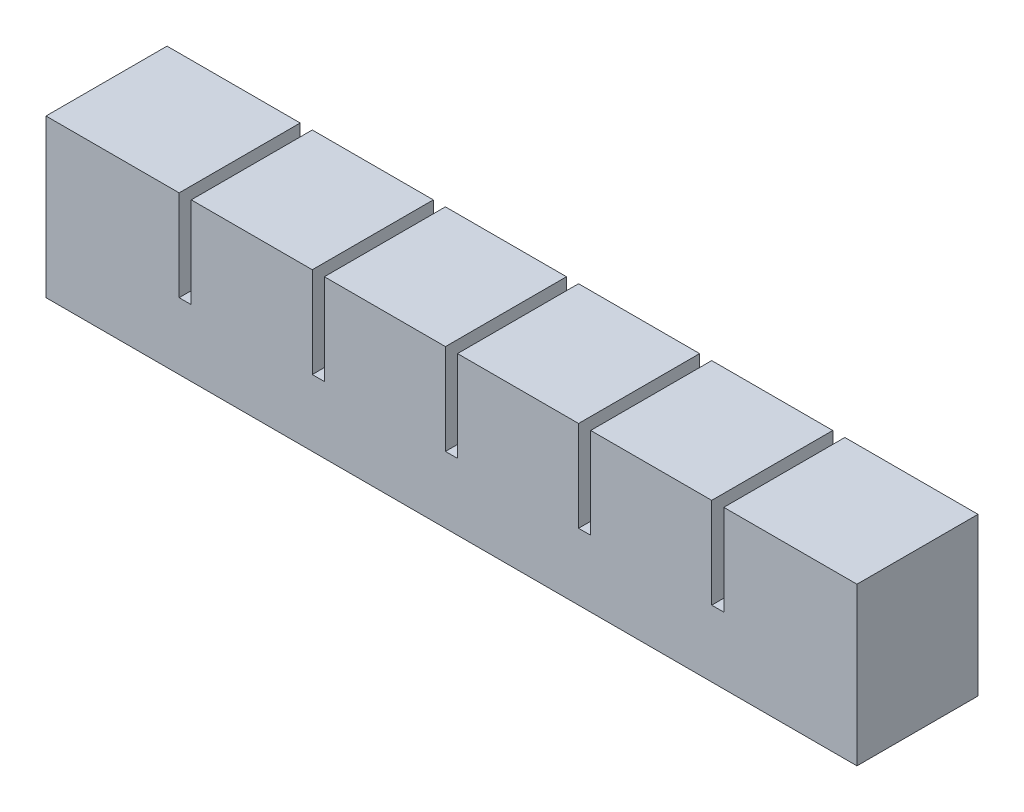
from build123d import *

# Parameters (mm, degrees)
SKETCH1_W           = 20
SKETCH1_H           = 20
BOSS_EXTRUDE1_DEPTH = 20
SKETCH2_W           = 10
SKETCH2_H           = 10
CUT_EXTRUDE1_DEPTH  = 15
SKETCH3_W           = 20
SKETCH3_H           = 5
BOSS_EXTRUDE2_DEPTH = 2
LPATTERN1_COUNT     = 6
LPATTERN1_PITCH     = 22
SKETCH4_W           = 20
SKETCH4_H           = 15
BOSS_EXTRUDE3_DEPTH = 2
SKETCH5_W           = 20
SKETCH5_H           = 20
BOSS_EXTRUDE5_DEPTH = 2
SKETCH7_W           = 120
SKETCH7_H           = 2
CUT_EXTRUDE2_DEPTH  = 2
SKETCH8_W           = 134
SKETCH8_H           = 20
BOSS_EXTRUDE6_DEPTH = 6


with BuildPart() as part:
    # Sketch1 → Boss-Extrude1 (new body)
    with BuildSketch(Plane.XY):
        with Locations((10, 10)):
            Rectangle(SKETCH1_W, SKETCH1_H)
    extrude(amount=BOSS_EXTRUDE1_DEPTH)

    # Sketch2 → Cut-Extrude1 (cut)
    with BuildSketch(Plane(origin=(0, 0, 0), x_dir=(-1, 0, 0), z_dir=(0, -1, 0))):
        with Locations((-10, -10)):
            Rectangle(SKETCH2_W, SKETCH2_H)
    extrude(amount=-CUT_EXTRUDE1_DEPTH, mode=Mode.SUBTRACT)

    # Sketch3 → Boss-Extrude2 (add)
    with BuildSketch(Plane(origin=(20, 0, 0), x_dir=(0, 0, -1), z_dir=(1, 0, 0))):
        with Locations((-10, 2.5)):
            Rectangle(SKETCH3_W, SKETCH3_H)
    extrude(amount=BOSS_EXTRUDE2_DEPTH)


with BuildPart() as lpattern1_1:
    # LPattern1: pattern copy
    add(part.part.moved(Location(Vector(1, 0, 0) * (1 * LPATTERN1_PITCH))))


with BuildPart() as lpattern1_2:
    # LPattern1: pattern copy
    add(part.part.moved(Location(Vector(1, 0, 0) * (2 * LPATTERN1_PITCH))))


with BuildPart() as lpattern1_3:
    # LPattern1: pattern copy
    add(part.part.moved(Location(Vector(1, 0, 0) * (3 * LPATTERN1_PITCH))))


with BuildPart() as lpattern1_4:
    # LPattern1: pattern copy
    add(part.part.moved(Location(Vector(1, 0, 0) * (4 * LPATTERN1_PITCH))))


with BuildPart() as lpattern1_5:
    # LPattern1: pattern copy
    add(part.part.moved(Location(Vector(1, 0, 0) * (5 * LPATTERN1_PITCH))))


with BuildPart() as lpattern1_1_1:
    add(lpattern1_1.part)

    # Combine1: union LPattern1_2, LPattern1_3, part, LPattern1_4, LPattern1_5
    add(lpattern1_2.part)
    add(lpattern1_3.part)
    add(part.part)
    add(lpattern1_4.part)
    add(lpattern1_5.part)

    # Sketch4 → Boss-Extrude3 (add)
    with BuildSketch(Plane(origin=(130, 0, 0), x_dir=(0, 0, -1), z_dir=(1, 0, 0))):
        with Locations((-10, 12.5)):
            Rectangle(SKETCH4_W, SKETCH4_H)
    extrude(amount=BOSS_EXTRUDE3_DEPTH)

    # Sketch5 → Boss-Extrude5 (add)
    with BuildSketch(Plane.ZY):
        with Locations((10, 10)):
            Rectangle(SKETCH5_W, SKETCH5_H)
    extrude(amount=BOSS_EXTRUDE5_DEPTH)

    # Sketch7 → Cut-Extrude2 (cut)
    with BuildSketch(Plane(origin=(0, 0, 0), x_dir=(-1, 0, 0), z_dir=(0, -1, 0))):
        with Locations((-65, -10)):
            Rectangle(SKETCH7_W, SKETCH7_H)
    extrude(amount=-CUT_EXTRUDE2_DEPTH, mode=Mode.SUBTRACT)

    # Sketch8 → Boss-Extrude6 (add)
    with BuildSketch(Plane.XZ):
        with Locations((65, 10)):
            Rectangle(SKETCH8_W, SKETCH8_H)
    extrude(amount=BOSS_EXTRUDE6_DEPTH)


solid = lpattern1_1_1.part
